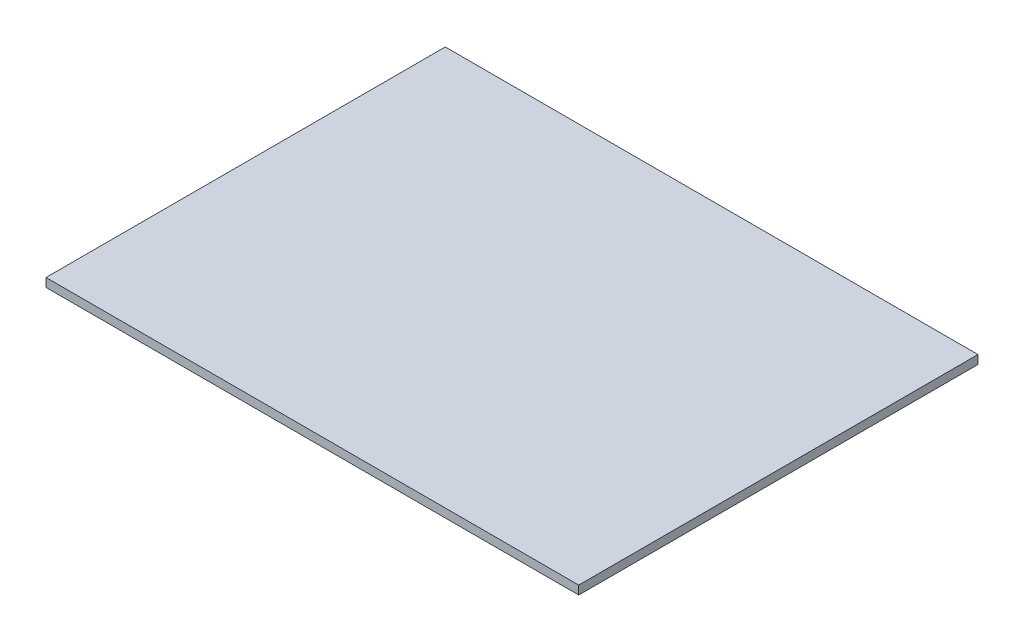
from build123d import *

# Parameters (mm, degrees)
SKETCH1_W           = 3078
SKETCH1_H           = 2307
BOSS_EXTRUDE1_DEPTH = 50


with BuildPart() as part:
    # Sketch1 → Boss-Extrude1 (new body)
    with BuildSketch(Plane(origin=(0, 0, 0), x_dir=(1, 0, 0), z_dir=(0, 1, 0))):
        with Locations((-515.283829315, 524.729411765)):
            Rectangle(SKETCH1_W, SKETCH1_H)
    extrude(amount=BOSS_EXTRUDE1_DEPTH)


solid = part.part
